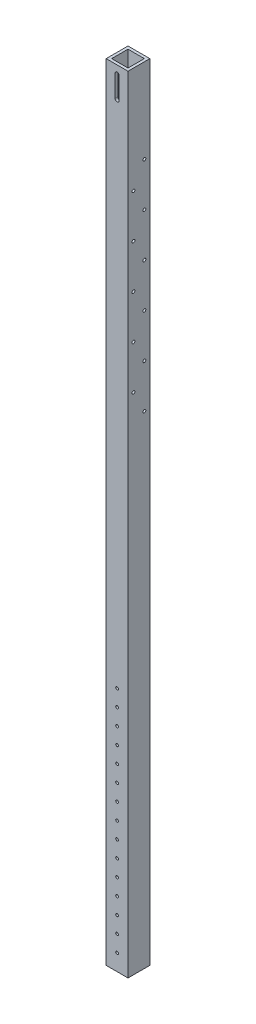
from build123d import *

# Parameters (mm, degrees)
SKETCH1_W           = 25.4
SKETCH1_H           = 25.4
SKETCH1_W_2         = 19.05
SKETCH1_H_2         = 19.05
BOSS_EXTRUDE1_DEPTH = 914.4
CUT_EXTRUDE1_REACH  = 27.4
SKETCH4_R           = 1.7145
CUT_EXTRUDE3_DEPTH  = 26.4
SKETCH6_R           = 1.5875
CUT_EXTRUDE5_DEPTH  = 26.4


with BuildPart() as part:
    # Sketch1 → Boss-Extrude1 (new body)
    with BuildSketch(Plane(origin=(0, 0, 0), x_dir=(1, 0, 0), z_dir=(0, 1, 0))):
        Rectangle(SKETCH1_W, SKETCH1_H)
        Rectangle(SKETCH1_W_2, SKETCH1_H_2, mode=Mode.SUBTRACT)
    extrude(amount=BOSS_EXTRUDE1_DEPTH)

    # Sketch2 → Cut-Extrude1 (cut, up to next)
    with BuildSketch(Plane(origin=(0, 0, 12.7), x_dir=(-1, 0, 0), z_dir=(0, 0, -1)), mode=Mode.PRIVATE) as cut_extrude1_sk1:
        with BuildLine():
            Line((-2.38125, 879.475), (-2.38125, 904.875))
            ThreePointArc((-2.38125, 904.875), (0, 907.25625), (2.38125, 904.875))
            Line((2.38125, 904.875), (2.38125, 879.475))
            ThreePointArc((2.38125, 879.475), (0, 877.09375), (-2.38125, 879.475))
        make_face()
    cut_extrude1_tool1 = extrude(cut_extrude1_sk1.sketch, amount=CUT_EXTRUDE1_REACH, mode=Mode.PRIVATE) & part.part
    add(cut_extrude1_tool1.solids().sort_by_distance((0, 892.175, 12.7))[0], mode=Mode.SUBTRACT)

    # Sketch4 → Cut-Extrude3 (cut, through all)
    with BuildSketch(Plane.ZY.offset(12.7)):
        with Locations((-6.35, 561.975)):
            Circle(SKETCH4_R)
        with Locations((6.35, 587.375)):
            Circle(SKETCH4_R)
        with Locations((-6.35, 612.775)):
            Circle(SKETCH4_R)
        with Locations((6.35, 638.175)):
            Circle(SKETCH4_R)
        with Locations((-6.35, 663.575)):
            Circle(SKETCH4_R)
        with Locations((6.35, 688.975)):
            Circle(SKETCH4_R)
        with Locations((-6.35, 714.375)):
            Circle(SKETCH4_R)
        with Locations((6.35, 739.775)):
            Circle(SKETCH4_R)
        with Locations((-6.35, 765.175)):
            Circle(SKETCH4_R)
        with Locations((6.35, 790.575)):
            Circle(SKETCH4_R)
        with Locations((-6.35, 815.975)):
            Circle(SKETCH4_R)
    extrude(amount=-CUT_EXTRUDE3_DEPTH, mode=Mode.SUBTRACT)

    # Sketch6 → Cut-Extrude5 (cut, through all)
    with BuildSketch(Plane.XY.offset(12.7)):
        with Locations((0, 19.05)):
            Circle(SKETCH6_R)
        with Locations((0, 38.1)):
            Circle(SKETCH6_R)
        with Locations((0, 57.15)):
            Circle(SKETCH6_R)
        with Locations((0, 76.2)):
            Circle(SKETCH6_R)
        with Locations((0, 95.25)):
            Circle(SKETCH6_R)
        with Locations((0, 114.3)):
            Circle(SKETCH6_R)
        with Locations((0, 133.35)):
            Circle(SKETCH6_R)
        with Locations((0, 152.4)):
            Circle(SKETCH6_R)
        with Locations((0, 171.45)):
            Circle(SKETCH6_R)
        with Locations((0, 190.5)):
            Circle(SKETCH6_R)
        with Locations((0, 209.55)):
            Circle(SKETCH6_R)
        with Locations((0, 228.6)):
            Circle(SKETCH6_R)
        with Locations((0, 247.65)):
            Circle(SKETCH6_R)
        with Locations((0, 266.7)):
            Circle(SKETCH6_R)
        with Locations((0, 285.75)):
            Circle(SKETCH6_R)
    extrude(amount=-CUT_EXTRUDE5_DEPTH, mode=Mode.SUBTRACT)


solid = part.part
